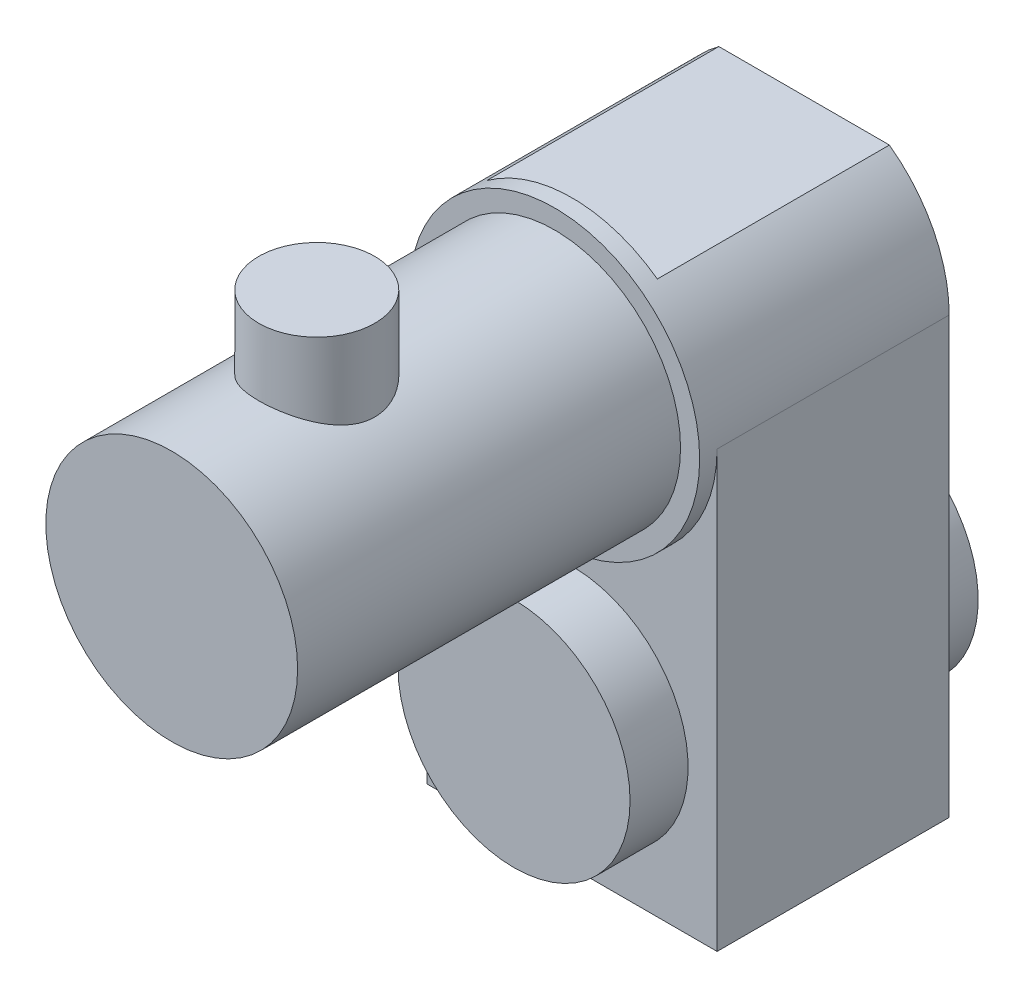
from build123d import *

# Parameters (mm, degrees)
SKETCH_1_R      = 125
EXTRUDE_1_DEPTH = 15
SKETCH_2_R      = 108.5
EXTRUDE_2_DEPTH = 330
SKETCH_4_W      = 50
SKETCH_4_H      = 70
EXTRUDE_4_DEPTH = 200
SKETCH_6_R      = 100
EXTRUDE_5_DEPTH = 50
SKETCH_7_R      = 100
EXTRUDE_6_DEPTH = 50


with BuildPart() as part:
    # 草图1 → 凸台-拉伸1 (new body)
    with BuildSketch(Plane.XY):
        Circle(SKETCH_1_R)
    extrude(amount=EXTRUDE_1_DEPTH)

    # 草图2 → 凸台-拉伸2 (add)
    with BuildSketch(Plane.XY.offset(15)):
        Circle(SKETCH_2_R)
    extrude(amount=EXTRUDE_2_DEPTH)

    # 草图4 → 旋转1 (revolve)
    with BuildSketch(Plane.XY.offset(220)):
        with Locations((-25, 131.292523074)):
            Rectangle(SKETCH_4_W, SKETCH_4_H)
    revolve(axis=Axis((0, 165.766992941, 220), (0, -1, 0)))

    # 草图5 → 凸台-拉伸4 (add)
    with BuildSketch(Plane(origin=(0, 0, 0), x_dir=(-1, 0, 0), z_dir=(0, 0, -1))):
        with BuildLine():
            Line((-73.496377584, 101.110249144), (73.496377584, 101.110249144))
            ThreePointArc((73.496377584, 101.110249144), (111.382330731, 56.736023838), (125, 0))
            Line((125, 0), (125, -375))
            Line((125, -375), (-125, -375))
            Line((-125, -375), (-125, 0))
            ThreePointArc((-125, 0), (-111.382330731, 56.736023838), (-73.496377584, 101.110249144))
        make_face()
    extrude(amount=EXTRUDE_4_DEPTH)

    # 草图6 → 凸台-拉伸5 (add)
    with BuildSketch(Plane(origin=(0, 0, -200), x_dir=(-1, 0, 0), z_dir=(0, 0, -1))):
        with Locations((0, -250)):
            Circle(SKETCH_6_R)
    extrude(amount=EXTRUDE_5_DEPTH)

    # 草图7 → 凸台-拉伸6 (add)
    with BuildSketch(Plane.XY):
        with Locations((0, -250)):
            Circle(SKETCH_7_R)
    extrude(amount=EXTRUDE_6_DEPTH)


solid = part.part
